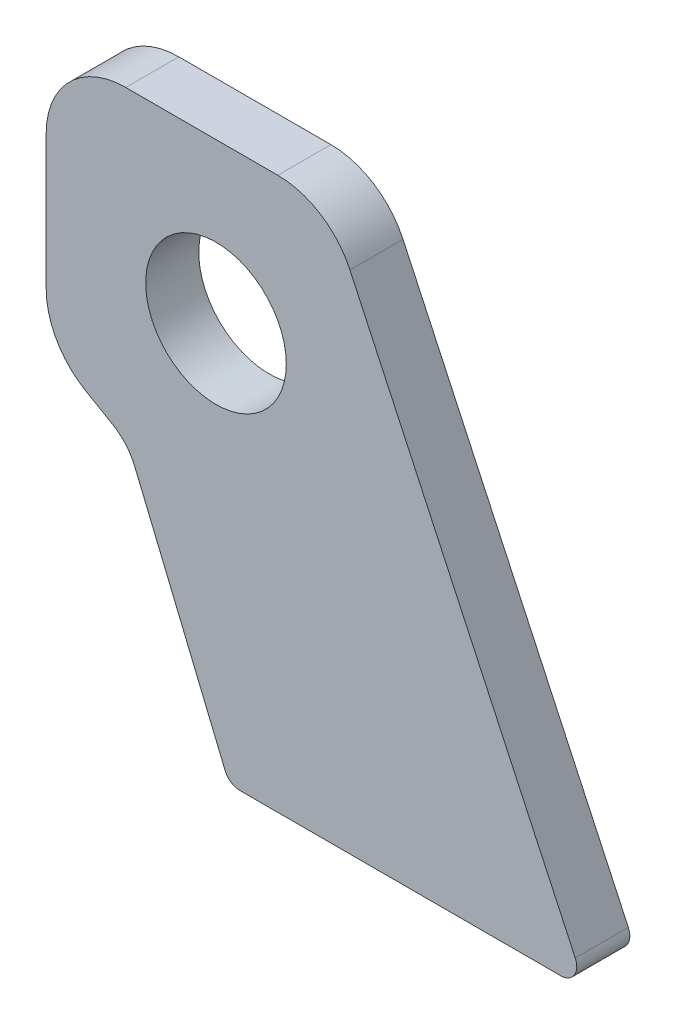
from build123d import *

# Parameters (mm, degrees)
SKETCH1_R      = 13.25
EXTRUDE1_DEPTH = 10


with BuildPart() as part:
    # Sketch1 → Extrude1 (new body)
    with BuildSketch(Plane.XY):
        with BuildLine():
            Line((-17, 29.999999993), (11.657006374, 29.999999993))
            ThreePointArc((11.657006374, 29.999999993), (19.7165005, 27.65087168), (25.25162318, 21.339273919))
            Line((25.25162318, 21.339273919), (67.718923361, -69.732145215))
            ThreePointArc((67.718923361, -69.732145215), (67.530174337, -72.611898825), (65, -74))
            Line((65, -74), (4.504535914, -74))
            ThreePointArc((4.504535914, -74), (2.837825215, -73.494408837), (1.732897316, -72.148050297))
            Line((1.732897316, -72.148050297), (-15.299509487, -31.028182792))
            ThreePointArc((-15.299509487, -31.028182792), (-17.019906738, -28.261558965), (-19.538304812, -26.194763078))
            Line((-19.538304812, -26.194763078), (-24.5, -23.330127026))
            ThreePointArc((-24.5, -23.330127026), (-29.990381057, -17.839745969), (-32, -10.339745969))
            Line((-32, -10.339745969), (-32, 14.999999993))
            ThreePointArc((-32, 14.999999993), (-27.606601718, 25.606601711), (-17, 29.999999993))
        make_face()
        Circle(SKETCH1_R, mode=Mode.SUBTRACT)
    extrude(amount=EXTRUDE1_DEPTH)


solid = part.part
